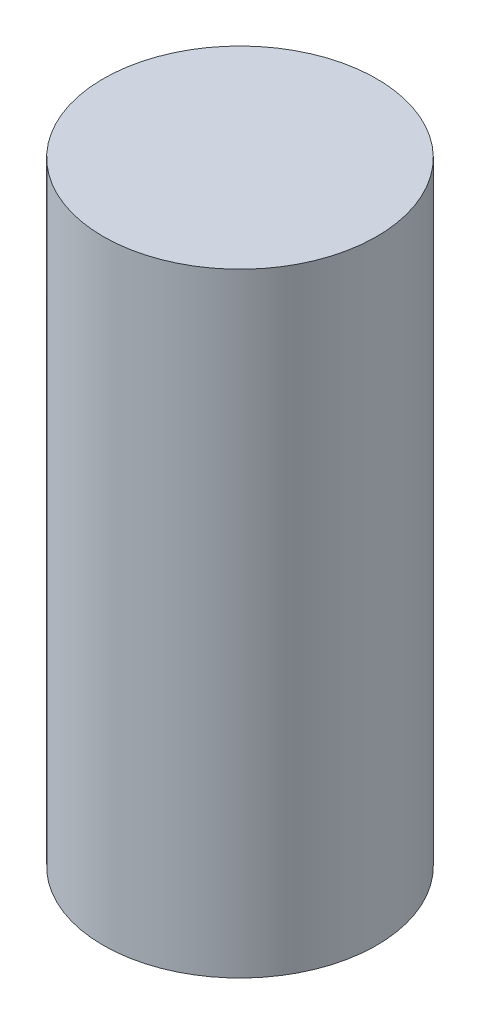
from build123d import *

# Parameters (mm, degrees)
SKETCH1_R           = 6.223
BOSS_EXTRUDE1_DEPTH = 27.94


with BuildPart() as part:
    # Sketch1 → Boss-Extrude1 (new body)
    with BuildSketch(Plane(origin=(0, 0, 0), x_dir=(1, 0, 0), z_dir=(0, 1, 0))):
        Circle(SKETCH1_R)
    extrude(amount=BOSS_EXTRUDE1_DEPTH)


solid = part.part
